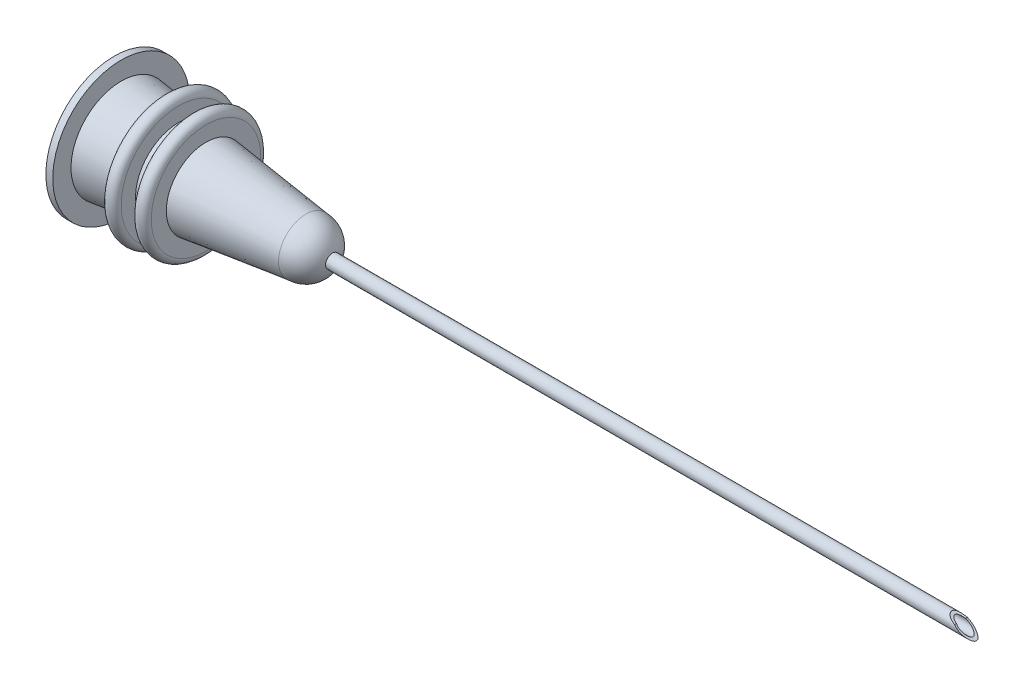
from build123d import *

# Parameters (mm, degrees)
DOME1_FACE_RADIUS   = 2
DOME1_HEIGHT        = 2
SKETCH2_R           = 0.5
CUT_EXTRUDE1_DEPTH  = 4
SKETCH3_R           = 0.5
SKETCH3_R_2         = 0.375
EXTRUDE_THIN1_DEPTH = 50
SKETCH4_R           = 3.5
CUT_EXTRUDE2_DEPTH  = 5
SKETCH5_R           = 5
CUT_EXTRUDE3_DEPTH  = 5


with BuildPart() as part:
    # Sketch1 → Revolve1 (revolve)
    with BuildSketch(Plane.XY):
        with BuildLine():
            Line((0, 0), (0, 2))
            Line((0, 2), (-7.3, 2.899560699))
            Line((-7.3, 2.899560699), (-7.3, 4))
            ThreePointArc((-7.3, 4), (-7.8, 4.5), (-8.3, 4))
            Line((-8.3, 4), (-8.3, 3.022788192))
            Line((-8.3, 3.022788192), (-9.3, 3.146015685))
            Line((-9.3, 3.146015685), (-9.3, 4.2))
            ThreePointArc((-9.3, 4.2), (-9.8, 4.7), (-10.3, 4.2))
            Line((-10.3, 4.2), (-10.3, 3.269243178))
            Line((-10.3, 3.269243178), (-13.5, 3.663571155))
            Line((-13.5, 3.663571155), (-13.5, 5))
            Line((-13.5, 5), (-14, 5))
            Line((-14, 5), (-14, 2.969511976))
            Line((-14, 2.969511976), (-1, 1.367554567))
            Line((-1, 1.367554567), (-1, 0))
            Line((-1, 0), (0, 0))
        make_face()
    revolve(axis=Axis((0, 0, 0), (-1, 0, 0)))

    # Dome1: a dome of height H over a round flat face of radius A is a cap of a sphere of radius (A * A + H * H) / (2 * H)
    dome1_r = (DOME1_FACE_RADIUS * DOME1_FACE_RADIUS + DOME1_HEIGHT * DOME1_HEIGHT) / (2 * DOME1_HEIGHT)
    dome1_base = Plane((0, 0, 0), z_dir=(1, 0, 0))
    with Locations(dome1_base.offset(DOME1_HEIGHT - dome1_r)):
        dome1_ball = Sphere(dome1_r, mode=Mode.PRIVATE)
    add(split(dome1_ball, bisect_by=dome1_base, keep=Keep.TOP, mode=Mode.PRIVATE))

    # Sketch2 → Cut-Extrude1 (cut)
    with BuildSketch(Plane.ZY.offset(1)):
        Circle(SKETCH2_R)
    extrude(amount=-CUT_EXTRUDE1_DEPTH, mode=Mode.SUBTRACT)

    # Sketch3 → Extrude-Thin1 (add)
    with BuildSketch(Plane.ZY.offset(1)):
        Circle(SKETCH3_R)
        Circle(SKETCH3_R_2, mode=Mode.SUBTRACT)
    extrude(amount=-EXTRUDE_THIN1_DEPTH)

    # Sketch4 → Cut-Extrude2 (cut, symmetric)
    with BuildSketch(Plane.XY):
        with Locations((49, 3.5)):
            Circle(SKETCH4_R)
    extrude(amount=CUT_EXTRUDE2_DEPTH, both=True, mode=Mode.SUBTRACT)

    # Sketch5 → Cut-Extrude3 (cut, symmetric)
    with BuildSketch(Plane.XY):
        with Locations((51, 4.082575695)):
            Circle(SKETCH5_R)
    extrude(amount=CUT_EXTRUDE3_DEPTH, both=True, mode=Mode.SUBTRACT)


solid = part.part
